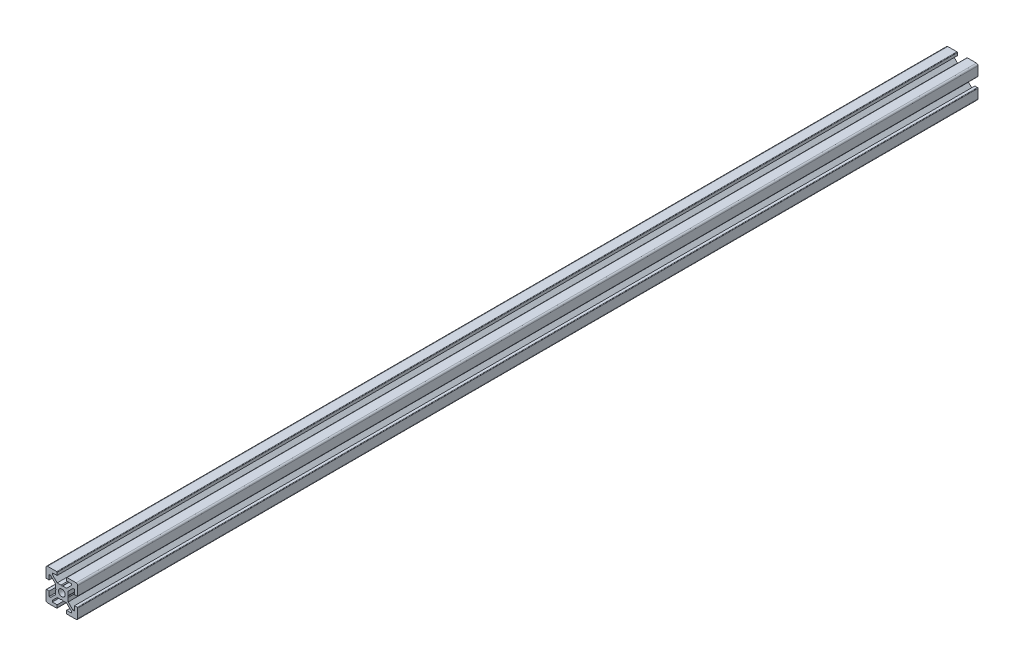
from build123d import *

# Parameters (mm, degrees)
BOSS_EXTRUDE1_DEPTH = 567.5
SKETCH2_W           = 567.5
SKETCH2_H           = 2.1
SKETCH4_R           = 2.5
CUT_EXTRUDE1_DEPTH  = 8


with BuildPart() as part:
    # Sketch1 → Boss-Extrude1 (new body)
    with BuildSketch(Plane.XY):
        with BuildLine():
            Line((-10, 9), (-10, 3.29999995))
            ThreePointArc((-10, 3.29999995), (-9.912132049, 3.087867916), (-9.7, 3))
            Line((-9.7, 3), (-8, 3))
            Line((-8, 3), (-8, 6))
            Line((-8, 6), (-7.060677, 6))
            Line((-7.060677, 6), (-4, 2.93932965))
            Line((-4, 2.93932965), (-4, 0.519615242))
            Line((-4, 0.519615242), (-3.699996283, -6.437e-06))
            Line((-3.699996283, -6.437e-06), (-4, -0.519628117))
            Line((-4, -0.519628117), (-4, -2.93933725))
            Line((-4, -2.93933725), (-7.0606695, -6))
            Line((-7.0606695, -6), (-8, -6))
            Line((-8, -6), (-8, -3))
            Line((-8, -3), (-9.7, -3))
            ThreePointArc((-9.7, -3), (-9.912132049, -3.087867916), (-10, -3.29999995))
            Line((-10, -3.29999995), (-10, -9))
            ThreePointArc((-10, -9), (-9.707106781, -9.707106781), (-9, -10))
            Line((-9, -10), (-3.29999995, -10))
            ThreePointArc((-3.29999995, -10), (-3.087867916, -9.912132049), (-3, -9.7))
            Line((-3, -9.7), (-3, -8))
            Line((-3, -8), (-6, -8))
            Line((-6, -8), (-6, -7.0606515))
            Line((-6, -7.0606515), (-2.9393489, -4))
            Line((-2.9393489, -4), (-0.519615242, -4))
            Line((-0.519615242, -4), (6.437e-06, -3.699996283))
            Line((6.437e-06, -3.699996283), (0.519628117, -4))
            Line((0.519628117, -4), (2.9393227, -4))
            Line((2.9393227, -4), (6, -7.060677))
            Line((6, -7.060677), (6, -8))
            Line((6, -8), (3, -8))
            Line((3, -8), (3, -9.7))
            ThreePointArc((3, -9.7), (3.087867916, -9.912132049), (3.29999995, -10))
            Line((3.29999995, -10), (9, -10))
            ThreePointArc((9, -10), (9.707106781, -9.707106781), (10, -9))
            Line((10, -9), (10, -3.29999995))
            ThreePointArc((10, -3.29999995), (9.912132049, -3.087867916), (9.7, -3))
            Line((9.7, -3), (8, -3))
            Line((8, -3), (8, -6))
            Line((8, -6), (7.0606435, -6))
            Line((7.0606435, -6), (4, -2.9393482))
            Line((4, -2.9393482), (4, -0.519615242))
            Line((4, -0.519615242), (3.699996283, 6.437e-06))
            Line((3.699996283, 6.437e-06), (4, 0.519628117))
            Line((4, 0.519628117), (4, 2.9393401))
            Line((4, 2.9393401), (7.060651, 6))
            Line((7.060651, 6), (8, 6))
            Line((8, 6), (8, 3))
            Line((8, 3), (9.7, 3))
            ThreePointArc((9.7, 3), (9.912132049, 3.087867916), (10, 3.29999995))
            Line((10, 3.29999995), (10, 9))
            ThreePointArc((10, 9), (9.707106781, 9.707106781), (9, 10))
            Line((9, 10), (3.29999995, 10))
            ThreePointArc((3.29999995, 10), (3.087867916, 9.912132049), (3, 9.7))
            Line((3, 9.7), (3, 8))
            Line((3, 8), (6, 8))
            Line((6, 8), (6, 7.060669))
            Line((6, 7.060669), (2.9393308, 4))
            Line((2.9393308, 4), (0.519615242, 4))
            Line((0.519615242, 4), (-6.437e-06, 3.699996283))
            Line((-6.437e-06, 3.699996283), (-0.519628117, 4))
            Line((-0.519628117, 4), (-2.93935655, 4))
            Line((-2.93935655, 4), (-6, 7.0606435))
            Line((-6, 7.0606435), (-6, 8))
            Line((-6, 8), (-3, 8))
            Line((-3, 8), (-3, 9.7))
            ThreePointArc((-3, 9.7), (-3.087867966, 9.912132034), (-3.3, 10))
            Line((-3.3, 10), (-9, 10))
            ThreePointArc((-9, 10), (-9.707106781, 9.707106781), (-10, 9))
        make_face()
    extrude(amount=-BOSS_EXTRUDE1_DEPTH)

    # Sketch2 → Cut-Revolve1 (revolve, cut)
    with BuildSketch(Plane(origin=(0, 0, 0), x_dir=(0, 0, -1), z_dir=(1, 0, 0))):
        with Locations((283.75, 1.05)):
            Rectangle(SKETCH2_W, SKETCH2_H)
    revolve(axis=Axis((0, 0, -567.5), (0, 0, 1)), mode=Mode.SUBTRACT)

    # Sketch4 → Cut-Extrude1 (cut)
    with BuildSketch(Plane(origin=(4, 0, 0), x_dir=(0, 0, -1), z_dir=(1, 0, 0))):
        with Locations((10, 6.437e-06)):
            Circle(SKETCH4_R)
        with Locations((557.5, 6.437e-06)):
            Circle(SKETCH4_R)
    extrude(amount=-CUT_EXTRUDE1_DEPTH, mode=Mode.SUBTRACT)


solid = part.part
